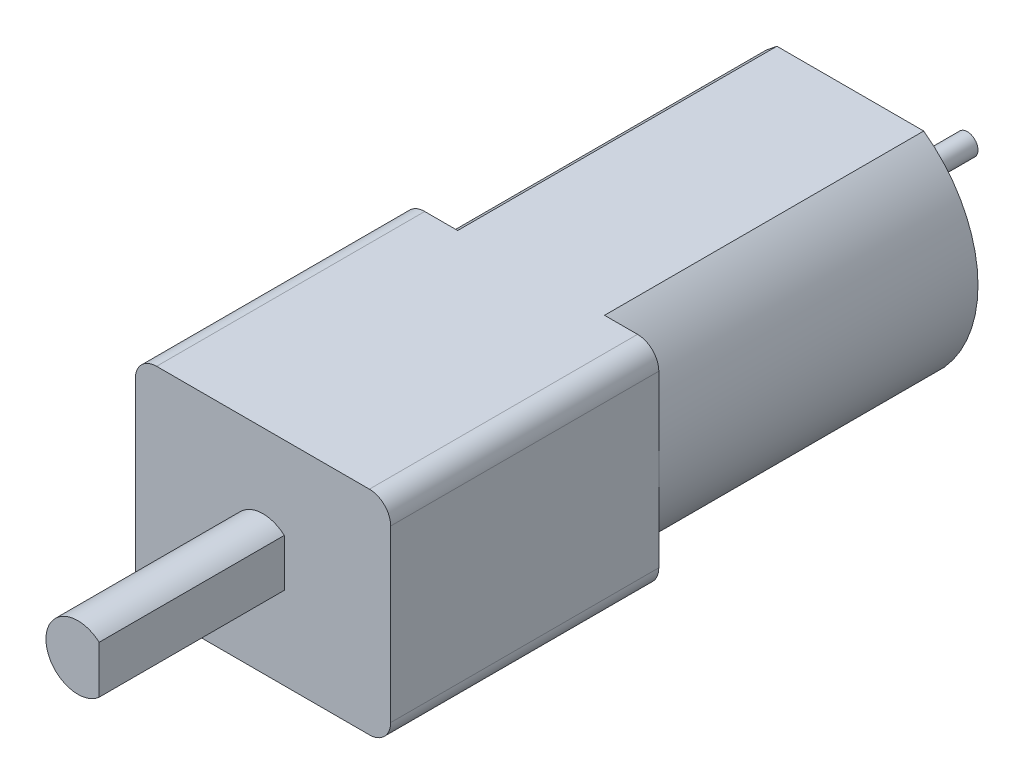
from build123d import *

# Parameters (mm, degrees)
BOSS_EXTRUDE1_DEPTH = 15
SKETCH2_W           = 12
SKETCH2_H           = 10
BOSS_EXTRUDE2_DEPTH = 12.6
FILLET1_R           = 1
BOSS_EXTRUDE3_DEPTH = 8.7
SKETCH4_R           = 2.5
BOSS_EXTRUDE4_DEPTH = 1.3
SKETCH5_R           = 0.5
BOSS_EXTRUDE5_DEPTH = 4.2


with BuildPart() as part:
    # Sketch1 → Boss-Extrude1 (new body)
    with BuildSketch(Plane.XY):
        with BuildLine():
            Line((-3.45, 5), (3.45, 5))
            ThreePointArc((3.45, 5), (6, 0), (3.45, -5))
            Line((3.45, -5), (-3.45, -5))
            ThreePointArc((-3.45, -5), (-6, 0), (-3.45, 5))
        make_face()
    extrude(amount=BOSS_EXTRUDE1_DEPTH)

    # Sketch2 → Boss-Extrude2 (add)
    with BuildSketch(Plane.XY.offset(15)):
        Rectangle(SKETCH2_W, SKETCH2_H)
    extrude(amount=BOSS_EXTRUDE2_DEPTH)

    # Fillet1
    fillet1_edges = [part.edges().sort_by_distance(p)[0] for p in [
        (6, -5, 21.3),
        (6, 5, 21.3),
        (-6, 5, 21.3),
        (-6, -5, 21.3),
    ]]
    fillet(fillet1_edges, radius=FILLET1_R)

    # Sketch3 → Boss-Extrude3 (add)
    with BuildSketch(Plane.XY.offset(27.6)):
        with BuildLine():
            Line((1, 1.118033989), (1, -1.118033989))
            ThreePointArc((1, -1.118033989), (-1.5, 0), (1, 1.118033989))
        make_face()
    extrude(amount=BOSS_EXTRUDE3_DEPTH)

    # Sketch4 → Boss-Extrude4 (add)
    with BuildSketch(Plane(origin=(0, 0, 0), x_dir=(-1, 0, 0), z_dir=(0, 0, -1))):
        Circle(SKETCH4_R)
    extrude(amount=BOSS_EXTRUDE4_DEPTH)

    # Sketch5 → Boss-Extrude5 (add)
    with BuildSketch(Plane(origin=(0, 0, -1.3), x_dir=(-1, 0, 0), z_dir=(0, 0, -1))):
        Circle(SKETCH5_R)
    extrude(amount=BOSS_EXTRUDE5_DEPTH)


solid = part.part
